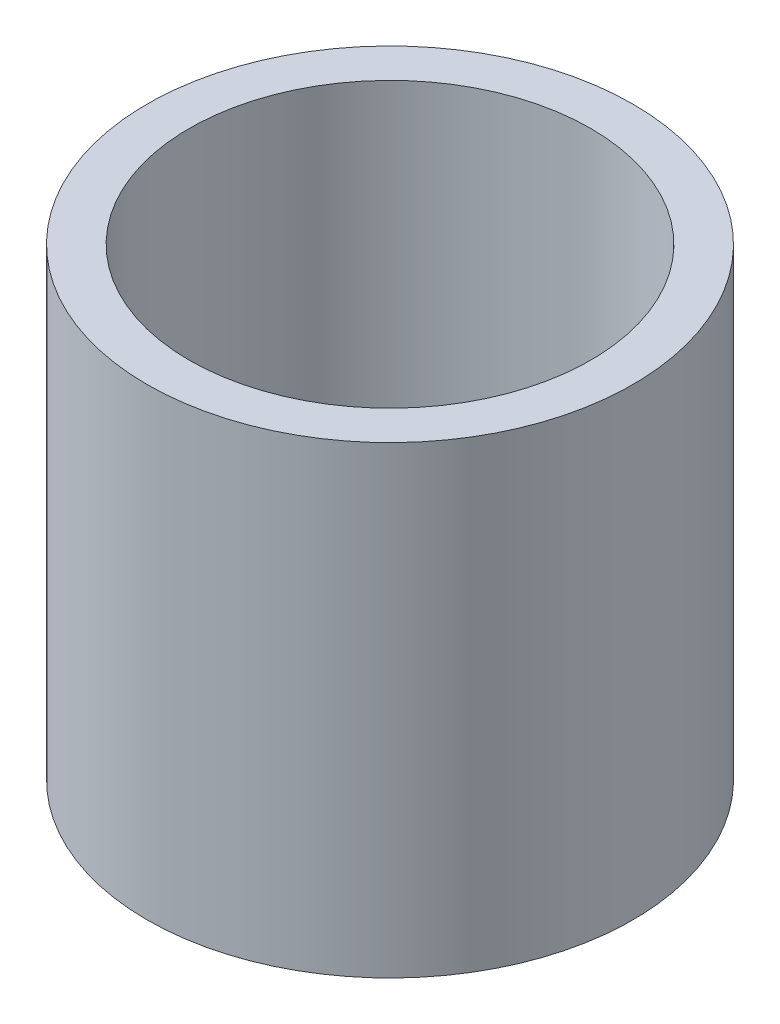
from build123d import *

# Parameters (mm, degrees)
SKETCH2_R           = 5.7625
BOSS_EXTRUDE1_DEPTH = 1
SKETCH3_R           = 5.7625
SKETCH3_R_2         = 4.7625
BOSS_EXTRUDE2_DEPTH = 10


with BuildPart() as part:
    # Sketch2 → Boss-Extrude1 (new body)
    with BuildSketch(Plane(origin=(0, 0, 0), x_dir=(1, 0, 0), z_dir=(0, 1, 0))):
        Circle(SKETCH2_R)
    extrude(amount=BOSS_EXTRUDE1_DEPTH)

    # Sketch3 → Boss-Extrude2 (add)
    with BuildSketch(Plane(origin=(0, 1, 0), x_dir=(1, 0, 0), z_dir=(0, 1, 0))):
        Circle(SKETCH3_R)
        Circle(SKETCH3_R_2, mode=Mode.SUBTRACT)
    extrude(amount=BOSS_EXTRUDE2_DEPTH)


solid = part.part
